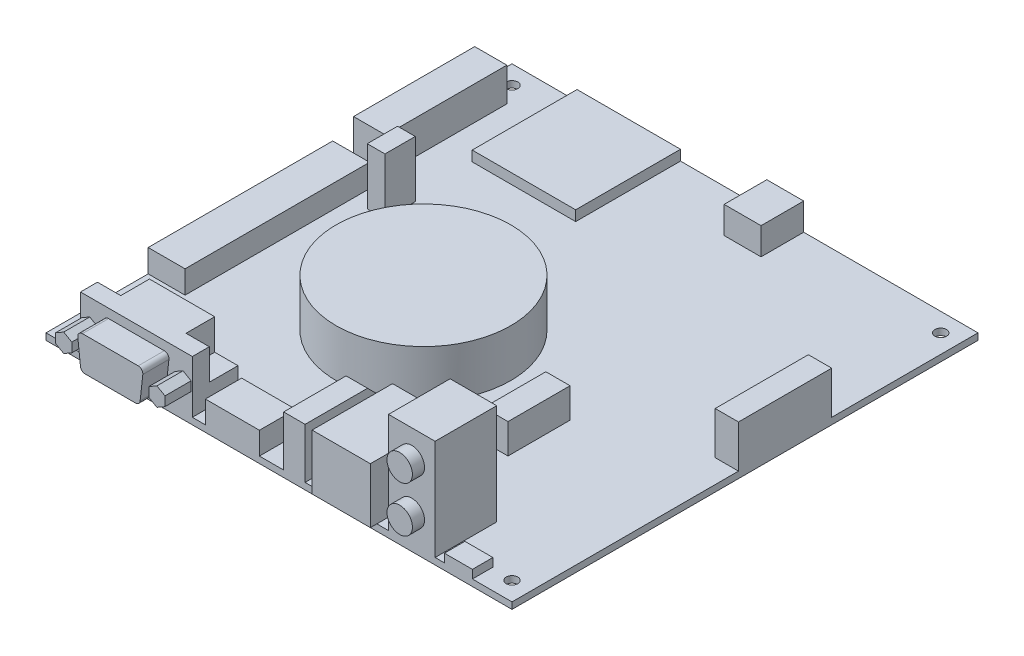
from build123d import *

# Parameters (mm, degrees)
SKETCH1_W            = 127
SKETCH1_H            = 127
SKETCH1_R            = 1.5875
BOSS_EXTRUDE1_DEPTH  = 1.778
SKETCH2_W            = 28.194
SKETCH2_H            = 28.575
BOSS_EXTRUDE2_DEPTH  = 2.794
SKETCH3_W            = 10.0584
SKETCH3_H            = 11.6332
BOSS_EXTRUDE3_DEPTH  = 7.366
SKETCH4_W            = 6.35
SKETCH4_H            = 25.4
BOSS_EXTRUDE4_DEPTH  = 11.6078
SKETCH5_W            = 8.763
SKETCH5_H            = 33.02
BOSS_EXTRUDE5_DEPTH  = 9.144
SKETCH6_W            = 10.0584
SKETCH6_H            = 50.292
BOSS_EXTRUDE6_DEPTH  = 6.223
SKETCH7_W            = 4.826
SKETCH7_H            = 8.255
BOSS_EXTRUDE7_DEPTH  = 15.3924
SKETCH8_W            = 7.62
SKETCH8_H            = 5.588
BOSS_EXTRUDE8_DEPTH  = 2.286
SKETCH9_R            = 23.8125
BOSS_EXTRUDE9_DEPTH  = 12.954
SKETCH10_W           = 12.7
SKETCH10_H           = 16.7894
BOSS_EXTRUDE10_DEPTH = 27.432
SKETCH11_R           = 3.4671
BOSS_EXTRUDE11_DEPTH = 3.302
SKETCH12_W           = 15.875
SKETCH12_H           = 21.9202
BOSS_EXTRUDE12_DEPTH = 15.0876
SKETCH13_W           = 5.842
SKETCH13_H           = 25.4
BOSS_EXTRUDE13_DEPTH = 13.716
CHAMFER1_SIZE        = 8.382
SKETCH14_W           = 14.732
SKETCH14_H           = 9.8806
BOSS_EXTRUDE14_DEPTH = 6.096
SKETCH15_W           = 6.604
SKETCH15_H           = 16.9164
BOSS_EXTRUDE15_DEPTH = 8.128
SKETCH16_W           = 30.48
SKETCH16_H           = 12.446
BOSS_EXTRUDE16_DEPTH = 14.351
SKETCH17_W           = 6.35
SKETCH17_H           = 7.8232
CUT_EXTRUDE1_DEPTH   = 8.382
BOSS_EXTRUDE17_DEPTH = 7.112


with BuildPart() as part:
    # Sketch1 → Boss-Extrude1 (new body)
    with BuildSketch(Plane(origin=(0, 0, 0), x_dir=(1, 0, 0), z_dir=(0, 1, 0))):
        with Locations((63.5, 63.5)):
            Rectangle(SKETCH1_W, SKETCH1_H)
        with Locations((5.08, 121.92)):
            Circle(SKETCH1_R, mode=Mode.SUBTRACT)
        with Locations((121.92, 121.92)):
            Circle(SKETCH1_R, mode=Mode.SUBTRACT)
        with Locations((121.92, 5.08)):
            Circle(SKETCH1_R, mode=Mode.SUBTRACT)
        with Locations((5.08, 5.08)):
            Circle(SKETCH1_R, mode=Mode.SUBTRACT)
    extrude(amount=BOSS_EXTRUDE1_DEPTH)

    # Sketch2 → Boss-Extrude2 (add)
    with BuildSketch(Plane(origin=(0, 1.778, 0), x_dir=(1, 0, 0), z_dir=(0, 1, 0))):
        with Locations((31.8262, 112.7125)):
            Rectangle(SKETCH2_W, SKETCH2_H)
    extrude(amount=BOSS_EXTRUDE2_DEPTH)

    # Sketch3 → Boss-Extrude3 (add)
    with BuildSketch(Plane(origin=(0, 1.778, 0), x_dir=(1, 0, 0), z_dir=(0, 1, 0))):
        with Locations((74.4728, 121.1834)):
            Rectangle(SKETCH3_W, SKETCH3_H)
    extrude(amount=BOSS_EXTRUDE3_DEPTH)

    # Sketch4 → Boss-Extrude4 (add)
    with BuildSketch(Plane(origin=(0, 1.778, 0), x_dir=(1, 0, 0), z_dir=(0, 1, 0))):
        with Locations((123.825, 74.422)):
            Rectangle(SKETCH4_W, SKETCH4_H)
    extrude(amount=BOSS_EXTRUDE4_DEPTH)

    # Sketch5 → Boss-Extrude5 (add)
    with BuildSketch(Plane(origin=(0, 1.778, 0), x_dir=(1, 0, 0), z_dir=(0, 1, 0))):
        with Locations((4.3815, 100.33)):
            Rectangle(SKETCH5_W, SKETCH5_H)
    extrude(amount=BOSS_EXTRUDE5_DEPTH)

    # Sketch6 → Boss-Extrude6 (add)
    with BuildSketch(Plane(origin=(0, 1.778, 0), x_dir=(1, 0, 0), z_dir=(0, 1, 0))):
        with Locations((5.0292, 52.9844)):
            Rectangle(SKETCH6_W, SKETCH6_H)
    extrude(amount=BOSS_EXTRUDE6_DEPTH)

    # Sketch7 → Boss-Extrude7 (add)
    with BuildSketch(Plane(origin=(0, 1.778, 0), x_dir=(1, 0, 0), z_dir=(0, 1, 0))):
        with Locations((16.9418, 77.1525)):
            Rectangle(SKETCH7_W, SKETCH7_H)
    extrude(amount=BOSS_EXTRUDE7_DEPTH)

    # Sketch8 → Boss-Extrude8 (add)
    with BuildSketch(Plane(origin=(0, 1.778, 0), x_dir=(1, 0, 0), z_dir=(0, 1, 0))):
        with Locations((112.395, 2.794)):
            Rectangle(SKETCH8_W, SKETCH8_H)
    extrude(amount=BOSS_EXTRUDE8_DEPTH)

    # Sketch9 → Boss-Extrude9 (add)
    with BuildSketch(Plane(origin=(0, 1.778, 0), x_dir=(1, 0, 0), z_dir=(0, 1, 0))):
        with Locations((50.8, 52.07)):
            Circle(SKETCH9_R)
    extrude(amount=BOSS_EXTRUDE9_DEPTH)

    # Sketch10 → Boss-Extrude10 (add)
    with BuildSketch(Plane(origin=(0, 1.778, 0), x_dir=(1, 0, 0), z_dir=(0, 1, 0))):
        with Locations((99.695, 8.3947)):
            Rectangle(SKETCH10_W, SKETCH10_H)
    extrude(amount=BOSS_EXTRUDE10_DEPTH)

    # Sketch11 → Boss-Extrude11 (add)
    with BuildSketch(Plane.XY):
        with Locations((99.695, 21.59)):
            Circle(SKETCH11_R)
        with Locations((99.695, 9.144)):
            Circle(SKETCH11_R)
    extrude(amount=BOSS_EXTRUDE11_DEPTH)

    # Sketch12 → Boss-Extrude12 (add)
    with BuildSketch(Plane(origin=(0, 1.778, 0), x_dir=(1, 0, 0), z_dir=(0, 1, 0))):
        with Locations((82.2325, 9.1821)):
            Rectangle(SKETCH12_W, SKETCH12_H)
    extrude(amount=BOSS_EXTRUDE12_DEPTH)

    # Sketch13 → Boss-Extrude13 (add)
    with BuildSketch(Plane(origin=(0, 1.778, 0), x_dir=(1, 0, 0), z_dir=(0, 1, 0))):
        with Locations((67.691, 12.7)):
            Rectangle(SKETCH13_W, SKETCH13_H)
    extrude(amount=BOSS_EXTRUDE13_DEPTH)

    # Chamfer1
    chamfer1_edges = [part.edges().sort_by_distance(p)[0] for p in [
        (67.691, 15.494, -25.4),
    ]]
    chamfer(chamfer1_edges, length=CHAMFER1_SIZE)

    # Sketch14 → Boss-Extrude14 (add)
    with BuildSketch(Plane(origin=(0, 1.778, 0), x_dir=(1, 0, 0), z_dir=(0, 1, 0))):
        with Locations((50.8, 4.9403)):
            Rectangle(SKETCH14_W, SKETCH14_H)
    extrude(amount=BOSS_EXTRUDE14_DEPTH)

    # Sketch15 → Boss-Extrude15 (add)
    with BuildSketch(Plane(origin=(0, 1.778, 0), x_dir=(1, 0, 0), z_dir=(0, 1, 0))):
        with Locations((88.7222, 42.3418)):
            Rectangle(SKETCH15_W, SKETCH15_H)
    extrude(amount=BOSS_EXTRUDE15_DEPTH)

    # Sketch16 → Boss-Extrude16 (add)
    with BuildSketch(Plane(origin=(0, 1.778, 0), x_dir=(1, 0, 0), z_dir=(0, 1, 0))):
        with Locations((24.638, 6.223)):
            Rectangle(SKETCH16_W, SKETCH16_H)
    extrude(amount=BOSS_EXTRUDE16_DEPTH)

    # Sketch17 → Cut-Extrude1 (cut)
    with BuildSketch(Plane(origin=(0, 16.129, 0), x_dir=(1, 0, 0), z_dir=(0, 1, 0))):
        with Locations((12.573, 8.5344)):
            Rectangle(SKETCH17_W, SKETCH17_H)
        with Locations((36.703, 8.5344)):
            Rectangle(SKETCH17_W, SKETCH17_H)
    extrude(amount=-CUT_EXTRUDE1_DEPTH, mode=Mode.SUBTRACT)

    # Sketch18 → Boss-Extrude17 (add)
    with BuildSketch(Plane.XY):
        Polygon((11.938, 11.4935), (9.738295474, 10.2235), (9.738295474, 7.6835), (11.938, 6.4135), (14.137704526, 7.6835), (14.137704526, 10.2235), align=None)
        Polygon((37.338, 11.4935), (35.138295474, 10.2235), (35.138295474, 7.6835), (37.338, 6.4135), (39.537704526, 7.6835), (39.537704526, 10.2235), align=None)
        with BuildLine():
            Line((17.039926569, 13.665748038), (32.236073431, 13.665748038))
            ThreePointArc((32.236073431, 13.665748038), (33.182386013, 13.242738295), (33.498305774, 12.2555))
            Line((33.498305774, 12.2555), (32.764527996, 5.6515))
            ThreePointArc((32.764527996, 5.6515), (32.34928591, 4.845435455), (31.502295653, 4.521748038))
            Line((31.502295653, 4.521748038), (17.773704347, 4.521748038))
            ThreePointArc((17.773704347, 4.521748038), (16.92671409, 4.845435455), (16.511472004, 5.6515))
            Line((16.511472004, 5.6515), (15.777694226, 12.2555))
            ThreePointArc((15.777694226, 12.2555), (16.093613987, 13.242738295), (17.039926569, 13.665748038))
        make_face()
    extrude(amount=BOSS_EXTRUDE17_DEPTH)


solid = part.part
